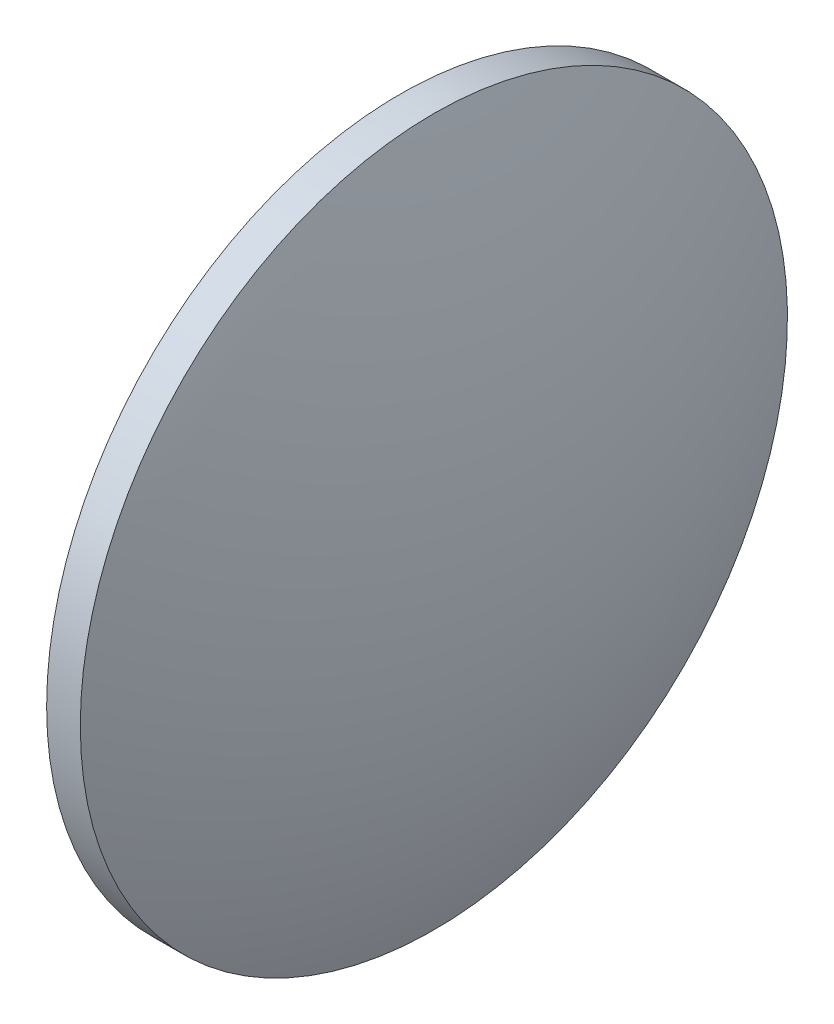
from build123d import *


with BuildPart() as part:
    # 草图2 → 旋转1 (revolve)
    with BuildSketch(Plane.XY):
        with BuildLine():
            Line((226.893301001, 130.518581457), (226.893301001, 162.018581457))
            Line((226.893301001, 162.018581457), (229.893301001, 162.018581457))
            ThreePointArc((229.893301001, 162.018581457), (234.558289844, 146.57463639), (236.133301001, 130.518581457))
            Line((236.133301001, 130.518581457), (226.893301001, 130.518581457))
        make_face()
    revolve(axis=Axis((218.123666737, 130.518581457, 0), (1, 0, 0)))


solid = part.part
